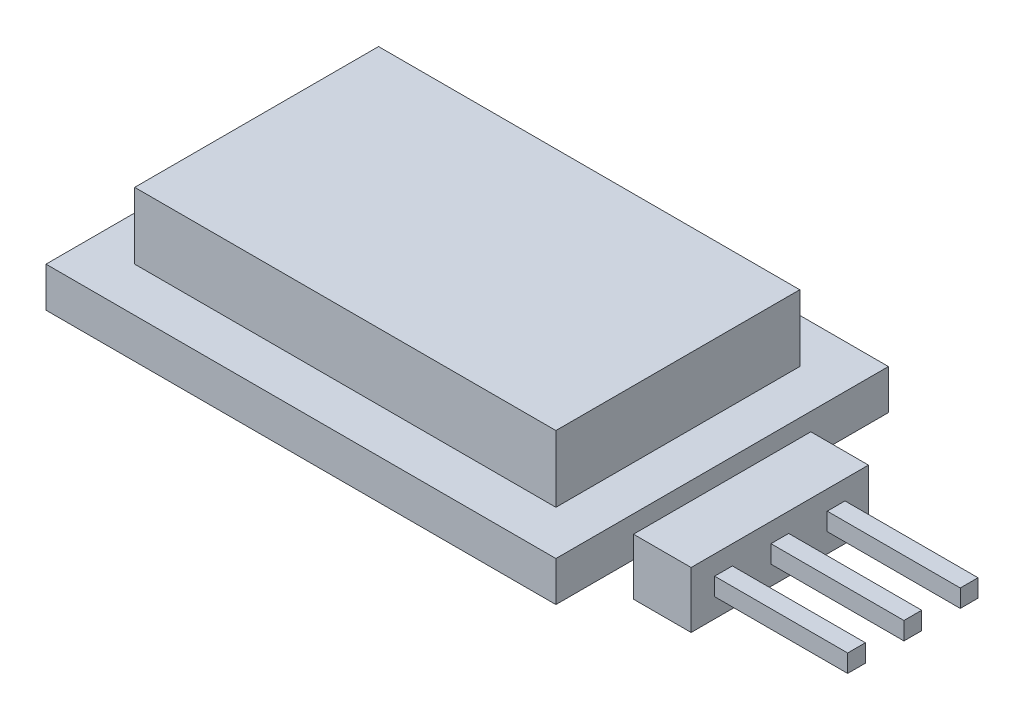
from build123d import *

# Parameters (mm, degrees)
CROQUIS1_W              = 23
CROQUIS1_H              = 15
SALIENTE_EXTRUIR1_DEPTH = 1.8
CROQUIS2_W              = 19
CROQUIS2_H              = 11
SALIENTE_EXTRUIR2_DEPTH = 3
CROQUIS3_W              = 8
CROQUIS3_H              = 2.54
SALIENTE_EXTRUIR3_DEPTH = 2.6
CROQUIS4_W              = 0.8
CROQUIS4_H              = 0.8
SALIENTE_EXTRUIR4_DEPTH = 6


with BuildPart() as part:
    # Croquis1 → Saliente-Extruir1 (new body)
    with BuildSketch(Plane(origin=(0, 0, 0), x_dir=(1, 0, 0), z_dir=(0, 1, 0))):
        with Locations((11.5, 7.5)):
            Rectangle(CROQUIS1_W, CROQUIS1_H)
    extrude(amount=SALIENTE_EXTRUIR1_DEPTH)

    # Croquis2 → Saliente-Extruir2 (add)
    with BuildSketch(Plane(origin=(0, 1.8, 0), x_dir=(1, 0, 0), z_dir=(0, 1, 0))):
        with Locations((11.5, 7.5)):
            Rectangle(CROQUIS2_W, CROQUIS2_H)
    extrude(amount=SALIENTE_EXTRUIR2_DEPTH)

    # Croquis3 → Saliente-Extruir3 (add)
    with BuildSketch(Plane(origin=(23, 0, 0), x_dir=(0, 0, -1), z_dir=(1, 0, 0))):
        with Locations((7.5, -0.27)):
            Rectangle(CROQUIS3_W, CROQUIS3_H)
    extrude(amount=SALIENTE_EXTRUIR3_DEPTH)

    # Croquis4 → Saliente-Extruir4 (add)
    with BuildSketch(Plane(origin=(25.6, 0, 0), x_dir=(0, 0, -1), z_dir=(1, 0, 0))):
        with Locations((10.04, -0.27)):
            Rectangle(CROQUIS4_W, CROQUIS4_H)
        with Locations((7.5, -0.27)):
            Rectangle(CROQUIS4_W, CROQUIS4_H)
        with Locations((4.96, -0.27)):
            Rectangle(CROQUIS4_W, CROQUIS4_H)
    extrude(amount=SALIENTE_EXTRUIR4_DEPTH)


solid = part.part
